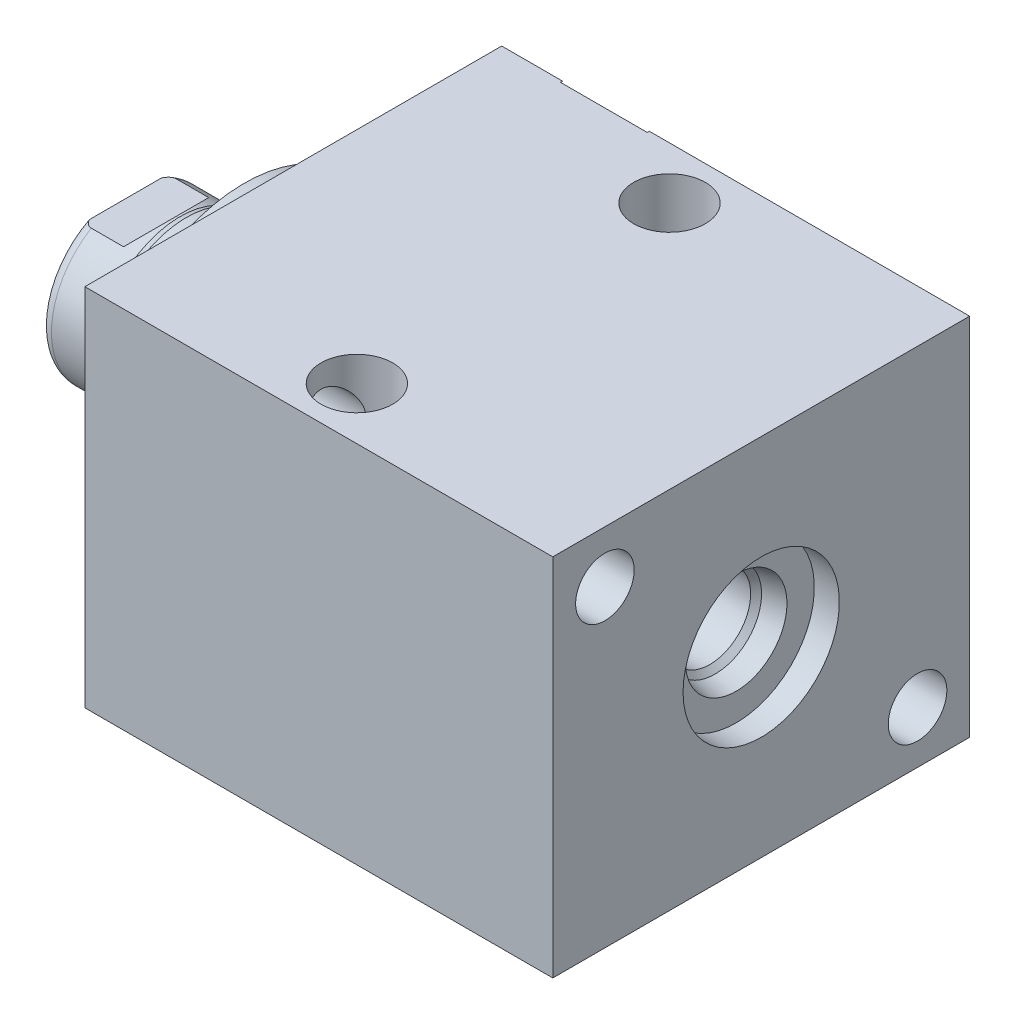
from build123d import *

# Parameters (mm, degrees)
SKETCH1_W          = 50.8
SKETCH1_H          = 44.45
EXTRUDE1_DEPTH     = 57.023
SKETCH5_R          = 17.4625
EXTRUDE2_DEPTH     = 5.969
SKETCH6_W          = 10.31875
SKETCH6_H          = 14.478
CUT_EXTRUDE4_DEPTH = 30.48
HOLE1_D            = 7.1374
HOLE1_DEPTH        = 57.023
HOLE2_D            = 8.7376
HOLE2_DEPTH        = 44.45


with BuildPart() as part:
    # Sketch1 → Extrude1 (new body)
    with BuildSketch(Plane(origin=(0, 0, 0), x_dir=(0, 0, -1), z_dir=(1, 0, 0))):
        Rectangle(SKETCH1_W, SKETCH1_H)
    extrude(amount=EXTRUDE1_DEPTH)

    # S2D0002 → Cut-Revolve1 (revolve, cut)
    with BuildSketch(Plane(origin=(0, 14.3002, 0), x_dir=(-1, 0, 0), z_dir=(0, 1, 0)), mode=Mode.PRIVATE) as cut_revolve1_sk:
        Polygon((-18.8849, -25.146), (-22.225, -25.146), (-22.225, -25.4), (-12.7, -25.4), (-12.7, -11.176), (-17.6784, -11.176), (-17.6784, -21.929393135), (-18.342306865, -22.5933), align=None)
    revolve(cut_revolve1_sk.sketch.rotate(Axis((12.7, 14.3002, -19.13842003), (0, 0, 1)), 180), axis=Axis((12.7, 14.3002, -19.13842003), (0, 0, 1)), mode=Mode.SUBTRACT)  # turned: the seam where the file's is

    # Sketch3 → Cut-Revolve2 (revolve, cut)
    with BuildSketch(Plane(origin=(41.148, 0, -25.146), x_dir=(1, 0, 0), z_dir=(0, 1, 0))):
        Polygon((6.1849, 0), (9.525, 0), (9.525, 0.254), (0, 0.254), (0, -13.97), (4.9784, -13.97), (4.9784, -3.216606865), (5.642306865, -2.5527), align=None)
    revolve(axis=Axis((41.148, 0, -3.189624441), (0, 0, -1)), mode=Mode.SUBTRACT)

    # Sketch4 → Cut-Revolve3 (revolve, cut)
    with BuildSketch(Plane(origin=(53.975, 0, 0), x_dir=(0, -1, 0), z_dir=(0, 0, 1)), mode=Mode.PRIVATE) as cut_revolve3_sk:
        Polygon((6.1849, 0), (9.525, 0), (9.525, 3.048), (0, 3.048), (0, -11.3538), (4.9784, -11.3538), (4.9784, -3.216606865), (5.642306865, -2.5527), align=None)
    revolve(cut_revolve3_sk.sketch.rotate(Axis((38.879609832, 0, 0), (1, 0, 0)), 270), axis=Axis((38.879609832, 0, 0), (1, 0, 0)), mode=Mode.SUBTRACT)  # turned: the seam where the file's is

    # Sketch5 → Extrude2 (add)
    with BuildSketch(Plane.ZY):
        Circle(SKETCH5_R)
    extrude(amount=EXTRUDE2_DEPTH)

    # Sketch6 → Revolve1 (revolve)
    with BuildSketch(Plane(origin=(0, 0, 0), x_dir=(0, 0, 1), z_dir=(0, -1, 0)), mode=Mode.PRIVATE) as revolve1_sk:
        with Locations((-5.159375, 13.208)):
            Rectangle(SKETCH6_W, SKETCH6_H)
    revolve(revolve1_sk.sketch.rotate(Axis((5.754582971, 0, 0), (-1, 0, 0)), 180), axis=Axis((5.754582971, 0, 0), (-1, 0, 0)))  # turned: the seam where the file's is

    # S2D0001 → Cut-Revolve4 (revolve, cut)
    with BuildSketch(Plane(origin=(-18.511260017, 3.2639, 0), x_dir=(0, 1, 0), z_dir=(0, 0, 1)), mode=Mode.PRIVATE) as cut_revolve4_sk:
        Polygon((0, 0), (0, -14.650460017), (-3.2639, -14.650460017), (-3.2639, 1.935739983), (1.1176, 1.935739983), align=None)
    revolve(cut_revolve4_sk.sketch.rotate(Axis((0, 0, 0), (-1, 0, 0)), 270), axis=Axis((0, 0, 0), (-1, 0, 0)), mode=Mode.SUBTRACT)  # turned: the seam where the file's is

    # Sketch8 → Cut-Revolve5 (revolve, cut)
    with BuildSketch(Plane(origin=(0, 0, 0), x_dir=(0, 0, -1), z_dir=(0, 1, 0)), mode=Mode.PRIVATE) as cut_revolve5_sk:
        with BuildLine():
            Line((-10.31875, 13.0302), (-10.033, 13.7922))
            Line((-10.033, 13.7922), (-10.033, 19.431))
            ThreePointArc((-10.033, 19.431), (-9.932678675, 19.974796865), (-9.644922533, 20.447))
            Line((-9.644922533, 20.447), (-10.31875, 20.447))
            Line((-10.31875, 20.447), (-10.31875, 13.0302))
        make_face()
    revolve(cut_revolve5_sk.sketch.rotate(Axis((-12.65936, 0, 0), (-1, 0, 0)), 180), axis=Axis((-12.65936, 0, 0), (-1, 0, 0)), mode=Mode.SUBTRACT)  # turned: the seam where the file's is

    # Sketch12 → Cut-Extrude4 (cut, symmetric)
    with BuildSketch(Plane(origin=(0, 0, 0), x_dir=(0, -1, 0), z_dir=(0, 0, -1))):
        Polygon((8.5852, 20.447), (8.5852, 15.494), (10.033, 14.0462), (10.033, 20.447), align=None)
        Polygon((-8.5852, 20.447), (-8.5852, 15.494), (-10.033, 14.0462), (-10.033, 20.447), align=None)
    extrude(amount=CUT_EXTRUDE4_DEPTH, both=True, mode=Mode.SUBTRACT)

    # Hole1
    with Locations(Plane.ZY):
        with Locations((-19.05, -15.875), (19.05, 15.875)):
            Hole(HOLE1_D / 2, depth=HOLE1_DEPTH)

    # Hole2
    with Locations(Plane(origin=(0, 22.225, 0), x_dir=(-1, 0, 0), z_dir=(0, 1, 0))):
        with Locations((-26.797, -19.05), (-26.797, 19.05)):
            Hole(HOLE2_D / 2, depth=HOLE2_DEPTH)


solid = part.part
